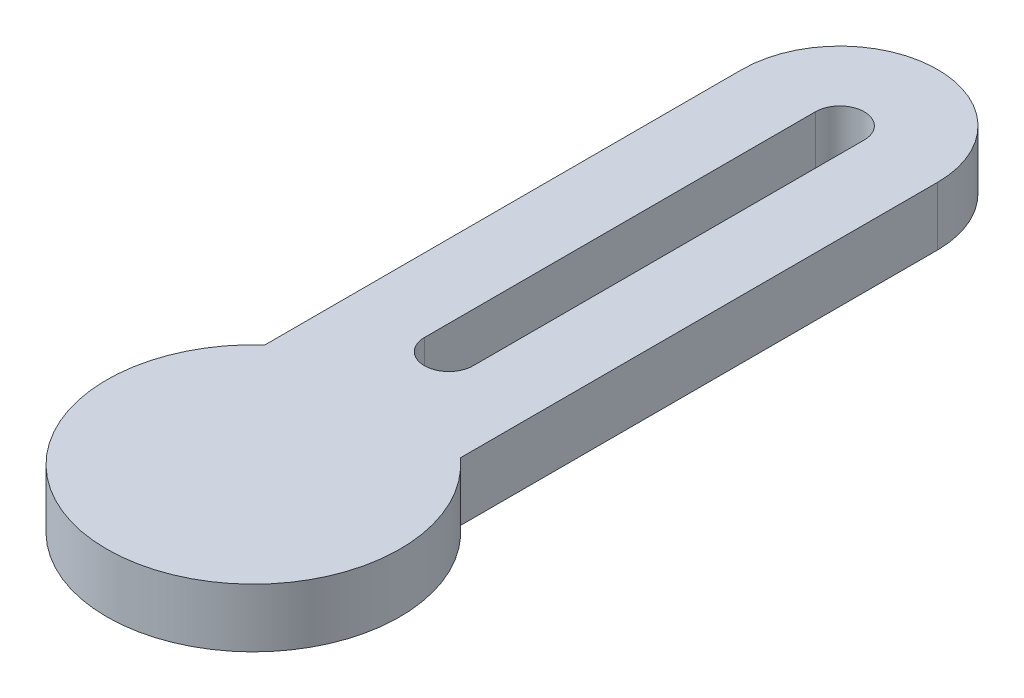
from build123d import *

# Parameters (mm, degrees)
BOSS_EXTRUDE1_DEPTH = 3


with BuildPart() as part:
    # Sketch1 → Boss-Extrude1 (new body)
    with BuildSketch(Plane(origin=(0, 0, 0), x_dir=(1, 0, 0), z_dir=(0, 1, 0))):
        with BuildLine():
            Line((-5, 30), (-5, 5.590169944))
            ThreePointArc((-5, 5.590169944), (0, 7.5), (5, 5.590169944))
            Line((5, 5.590169944), (5, 30))
            ThreePointArc((5, 30), (0, 35), (-5, 30))
        make_face()
        with BuildLine():
            ThreePointArc((-1.25, 30), (0, 31.25), (1.25, 30))
            Line((1.25, 30), (1.25, 10))
            ThreePointArc((1.25, 10), (0, 8.75), (-1.25, 10))
            Line((-1.25, 10), (-1.25, 30))
        make_face(mode=Mode.SUBTRACT)
        with BuildLine():
            ThreePointArc((5, 0), (0, -5), (-5, 0))
            Line((-5, 0), (-5, 5.590169944))
            ThreePointArc((-5, 5.590169944), (-3.061862178, -6.846531969), (7.5, 0))
            ThreePointArc((7.5, 0), (6.846531969, 3.061862178), (5, 5.590169944))
            Line((5, 5.590169944), (5, 0))
        make_face()
        with BuildLine():
            Line((-5, 5.590169944), (-5, 0))
            ThreePointArc((-5, 0), (0, -5), (5, 0))
            Line((5, 0), (5, 5.590169944))
            ThreePointArc((5, 5.590169944), (0, 7.5), (-5, 5.590169944))
        make_face()
    extrude(amount=BOSS_EXTRUDE1_DEPTH)


solid = part.part
